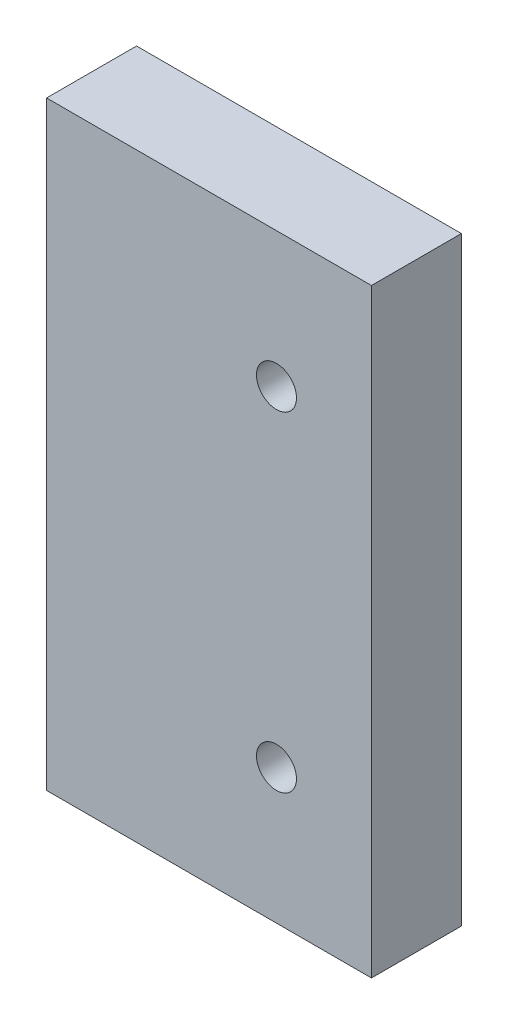
from build123d import *

# Parameters (mm, degrees)
SKETCH1_W           = 65
SKETCH1_H           = 120
SKETCH1_R           = 4
BOSS_EXTRUDE1_DEPTH = 18


with BuildPart() as part:
    # Sketch1 → Boss-Extrude1 (new body)
    with BuildSketch(Plane.XY):
        Rectangle(SKETCH1_W, SKETCH1_H)
        with Locations((13.5, 33)):
            Circle(SKETCH1_R, mode=Mode.SUBTRACT)
        with Locations((13.5, -33)):
            Circle(SKETCH1_R, mode=Mode.SUBTRACT)
    extrude(amount=BOSS_EXTRUDE1_DEPTH)


solid = part.part
